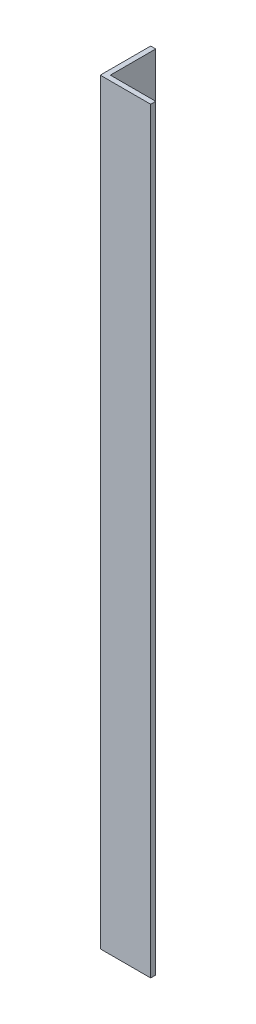
from build123d import *

# Parameters (mm, degrees)
EXTRUDE_1_DEPTH = 600


with BuildPart() as part:
    # Эскиз1 → Вытянуть-Тонкостенный1 (new body)
    with BuildSketch(Plane(origin=(0, 0, 0), x_dir=(1, 0, 0), z_dir=(0, 1, 0))):
        Polygon((0, 40), (0, 0), (40, 0), (40, 4), (4, 4), (4, 40), align=None)
    extrude(amount=EXTRUDE_1_DEPTH)


solid = part.part
